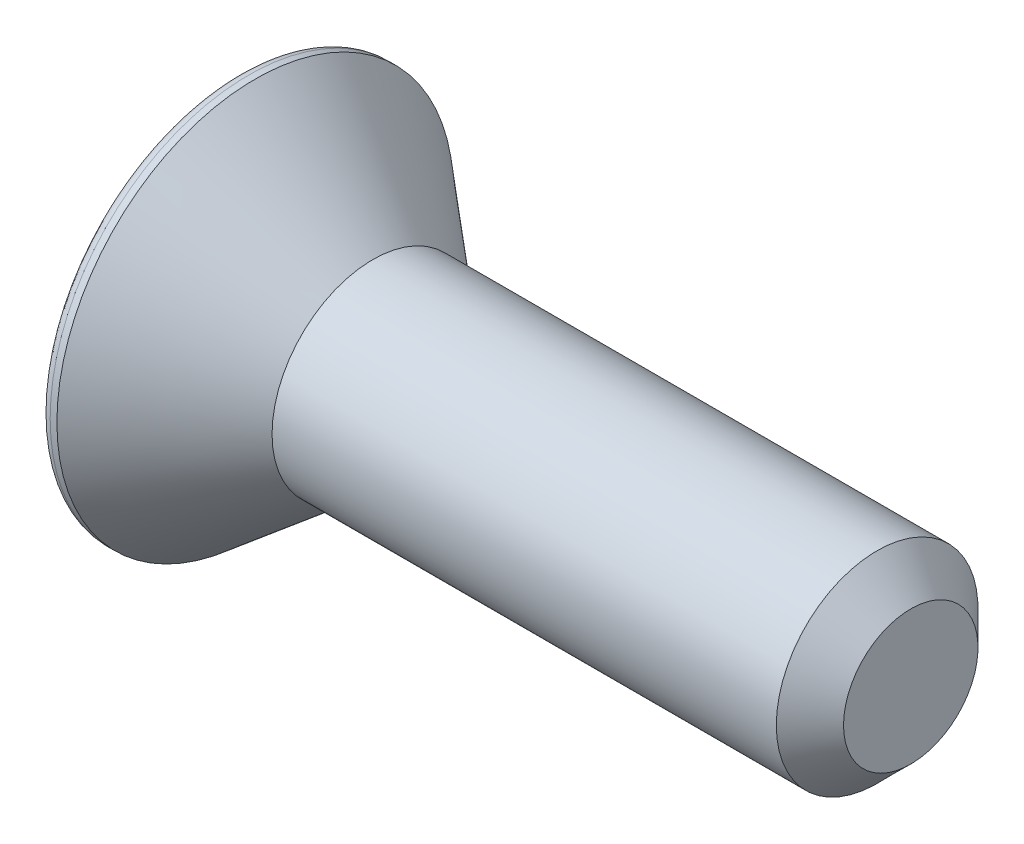
from build123d import *

# Parameters (mm, degrees)
CUT_EXTRUDE_1_DEPTH = 3
FILLET_1_R          = 0.3
CHAMFER_1_SIZE      = 1


with BuildPart() as part:
    # Эскиз1 → Повернуть1 (revolve)
    with BuildSketch(Plane.XY, mode=Mode.PRIVATE) as revolve_1_sk:
        Polygon((0, 0), (0, 5.9), (0.5, 5.9), (4, 3), (20, 3), (20, 0), align=None)
    revolve(revolve_1_sk.sketch.rotate(Axis((0, 0, 0), (1, 0, 0)), 90), axis=Axis((0, 0, 0), (1, 0, 0)))  # turned: the seam where the file's is

    # Эскиз2 → Вырез-Вытянуть1 (cut)
    with BuildSketch(Plane.ZY):
        Polygon((1.154700538, 2), (-1.154700538, 2), (-2.309401077, 0), (-1.154700538, -2), (1.154700538, -2), (2.309401077, 0), align=None)
    extrude(amount=-CUT_EXTRUDE_1_DEPTH, mode=Mode.SUBTRACT)

    # Скругление1
    fillet_1_edges = [part.edges().sort_by_distance(p)[0] for p in [
        (0, 0, -5.9),
    ]]
    fillet(fillet_1_edges, radius=FILLET_1_R)

    # Фаска1
    chamfer_1_edges = [part.edges().sort_by_distance(p)[0] for p in [
        (20, 0, -3),
    ]]
    chamfer(chamfer_1_edges, length=CHAMFER_1_SIZE)


solid = part.part
